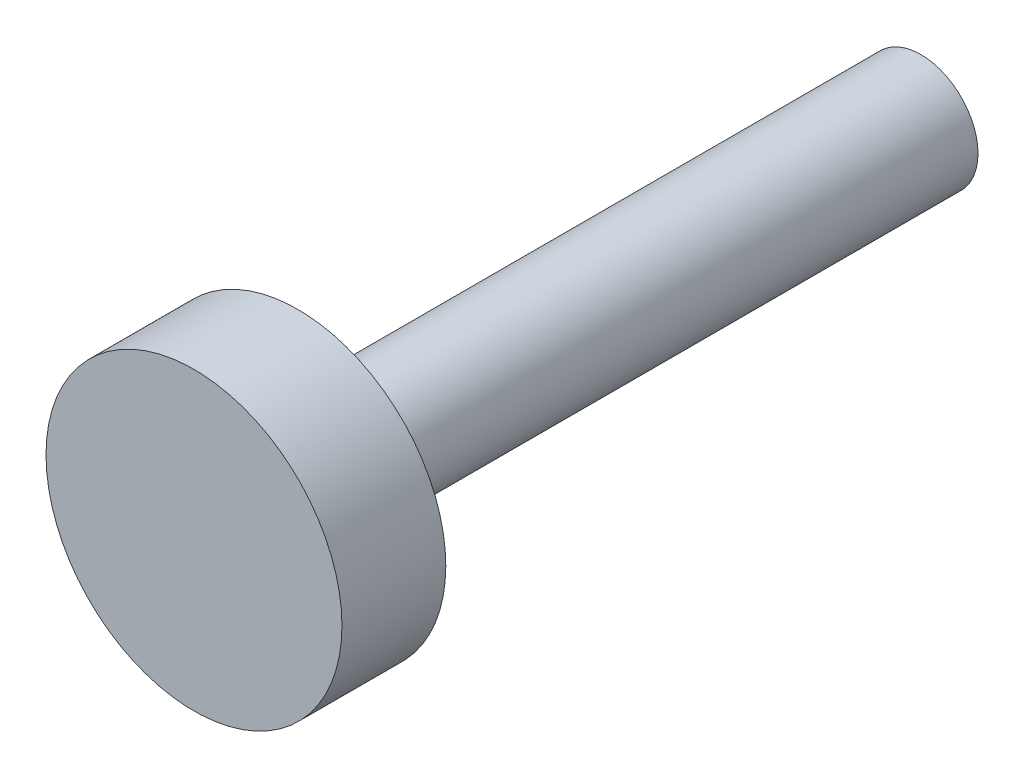
from build123d import *


with BuildPart() as part:
    # Skizze1 → Rotation1 (revolve)
    with BuildSketch(Plane(origin=(0, 0, 0), x_dir=(0, 0, -1), z_dir=(1, 0, 0))):
        Polygon((0, 0), (14, 0), (14, 1.1), (2, 1.1), (2, 2.85), (0, 2.85), align=None)
    revolve(axis=Axis((0, 0, 0), (0, 0, -1)))


solid = part.part
